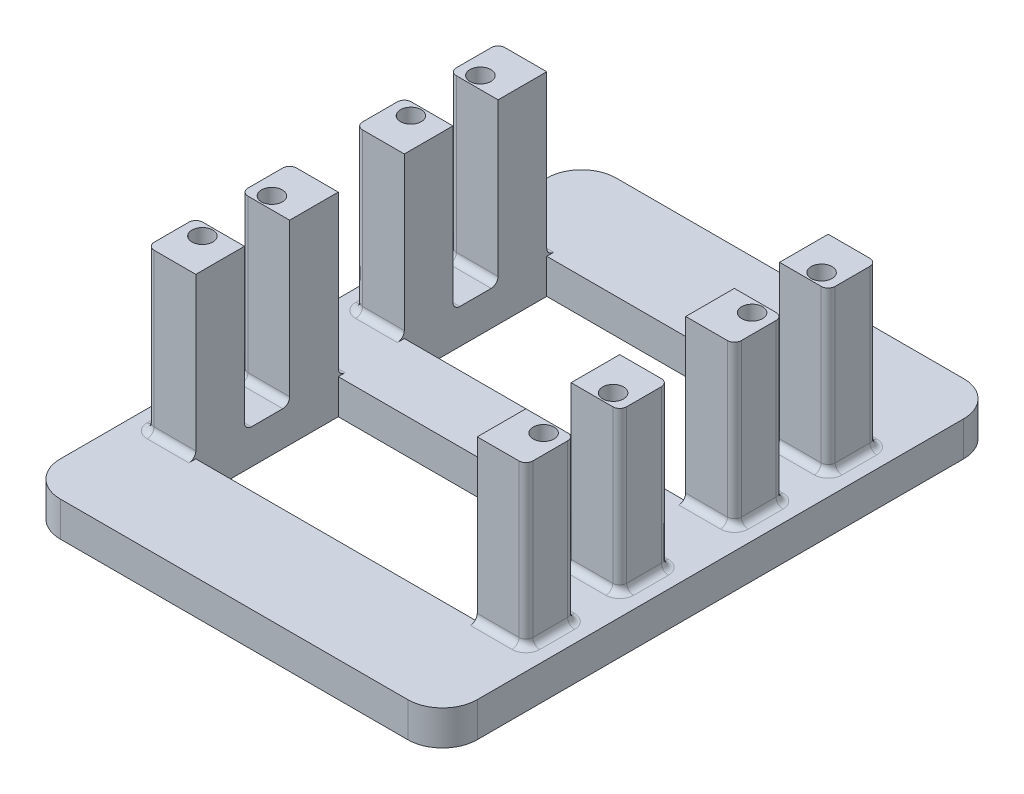
from build123d import *

# Parameters (mm, degrees)
SKETCH_1_W          = 60
SKETCH_1_H          = 80
EXTRUDE_1_DEPTH     = 5
SKETCH_2_W          = 40.5
SKETCH_2_H          = 20.5
CUT_EXTRUDE_1_DEPTH = 6
SKETCH_3_W          = 7
SKETCH_3_H          = 20.5
EXTRUDE_2_DEPTH     = 23
SKETCH_4_R          = 1.5
CUT_EXTRUDE_2_DEPTH = 10
FILLET_1_R          = 5
SKETCH_6_W          = 7
SKETCH_6_H          = 6.5
CUT_EXTRUDE_9_DEPTH = 23
FILLET_4_R          = 1
FILLET_6_R          = 1


with BuildPart() as part:
    # 草图1 → 凸台-拉伸1 (new body)
    with BuildSketch(Plane(origin=(0, 0, 0), x_dir=(1, 0, 0), z_dir=(0, 1, 0))):
        Rectangle(SKETCH_1_W, SKETCH_1_H)
    extrude(amount=EXTRUDE_1_DEPTH)

    # 草图2 → 切除-拉伸1 (cut, through all)
    with BuildSketch(Plane(origin=(0, 5, 0), x_dir=(1, 0, 0), z_dir=(0, 1, 0))):
        with Locations((0, -15)):
            Rectangle(SKETCH_2_W, SKETCH_2_H)
        with Locations((0, 15)):
            Rectangle(SKETCH_2_W, SKETCH_2_H)
    extrude(amount=-CUT_EXTRUDE_1_DEPTH, mode=Mode.SUBTRACT)

    # 草图3 → 凸台-拉伸2 (add)
    with BuildSketch(Plane(origin=(0, 5, 0), x_dir=(1, 0, 0), z_dir=(0, 1, 0))):
        with Locations((-23.75, 15)):
            Rectangle(SKETCH_3_W, SKETCH_3_H)
        with Locations((23.75, 15)):
            Rectangle(SKETCH_3_W, SKETCH_3_H)
        with Locations((23.75, -15)):
            Rectangle(SKETCH_3_W, SKETCH_3_H)
        with Locations((-23.75, -15)):
            Rectangle(SKETCH_3_W, SKETCH_3_H)
    extrude(amount=EXTRUDE_2_DEPTH)

    # 草图4 → 切除-拉伸2 (cut)
    with BuildSketch(Plane(origin=(0, 28, 0), x_dir=(1, 0, 0), z_dir=(0, 1, 0))):
        with Locations((-24.55, 20)):
            Circle(SKETCH_4_R)
        with Locations((-24.55, 10)):
            Circle(SKETCH_4_R)
        with Locations((24.55, 10)):
            Circle(SKETCH_4_R)
        with Locations((24.55, 20)):
            Circle(SKETCH_4_R)
        with Locations((24.55, -10)):
            Circle(SKETCH_4_R)
        with Locations((24.55, -20)):
            Circle(SKETCH_4_R)
        with Locations((-24.55, -10)):
            Circle(SKETCH_4_R)
        with Locations((-24.55, -20)):
            Circle(SKETCH_4_R)
    extrude(amount=-CUT_EXTRUDE_2_DEPTH, mode=Mode.SUBTRACT)

    # 圆角1
    fillet_1_edges = [part.edges().sort_by_distance(p)[0] for p in [
        (-30, 2.5, -40),
        (30, 2.5, -40),
        (30, 2.5, 40),
        (-30, 2.5, 40),
    ]]
    fillet(fillet_1_edges, radius=FILLET_1_R)

    # 草图6 → 切除-拉伸9 (cut)
    with BuildSketch(Plane(origin=(0, 28, 0), x_dir=(1, 0, 0), z_dir=(0, 1, 0))):
        with Locations((-23.75, 15)):
            Rectangle(SKETCH_6_W, SKETCH_6_H)
        with Locations((23.75, 15)):
            Rectangle(SKETCH_6_W, SKETCH_6_H)
        with Locations((23.75, -15)):
            Rectangle(SKETCH_6_W, SKETCH_6_H)
        with Locations((-23.75, -15)):
            Rectangle(SKETCH_6_W, SKETCH_6_H)
    extrude(amount=-CUT_EXTRUDE_9_DEPTH, mode=Mode.SUBTRACT)

    # 圆角4
    fillet_4_edges = [part.edges().sort_by_distance(p)[0] for p in [
        (-27.25, 16.5, 18.25),
        (-27.25, 16.5, 11.75),
        (27.25, 16.5, 11.75),
        (27.25, 16.5, 18.25),
        (27.25, 16.5, -18.25),
        (27.25, 16.5, -11.75),
        (-27.25, 16.5, -11.75),
        (-27.25, 16.5, -18.25),
        (-27.25, 16.5, -25.25),
        (-27.25, 16.5, -4.75),
        (27.25, 16.5, -4.75),
        (27.25, 16.5, -25.25),
        (27.25, 16.5, 25.25),
        (27.25, 16.5, 4.75),
        (-27.25, 16.5, 4.75),
        (-27.25, 16.5, 25.25),
    ]]
    fillet(fillet_4_edges, radius=FILLET_4_R)

    # 圆角6
    fillet_6_edges = [part.edges().sort_by_distance(p)[0] for p in [
        (-23.25, 5, 11.75),
        (23.25, 5, 18.25),
        (23.25, 5, -11.75),
        (-23.25, 5, -18.25),
        (23.25, 5, -25.25),
        (27.25, 5, -21.75),
        (23.25, 5, -18.25),
        (27.25, 5, -8.25),
        (23.25, 5, 4.75),
        (27.25, 5, 8.25),
        (23.25, 5, 11.75),
        (27.25, 5, 21.75),
        (-23.25, 5, 18.25),
        (-27.25, 5, 21.75),
        (-23.25, 5, 25.25),
        (-27.25, 5, 8.25),
        (-27.25, 5, -21.75),
        (-23.25, 5, -11.75),
        (-27.25, 5, -8.25),
        (-23.25, 5, -4.75),
        (26.957106781, 5, -24.957106781),
        (26.957106781, 5, -18.542893219),
        (26.957106781, 5, -11.457106781),
        (26.957106781, 5, -5.042893219),
        (26.957106781, 5, 5.042893219),
        (26.957106781, 5, 11.457106781),
        (26.957106781, 5, 18.542893219),
        (26.957106781, 5, 24.957106781),
        (-26.957106781, 5, 18.542893219),
        (-26.957106781, 5, 24.957106781),
        (-26.957106781, 5, 5.042893219),
        (-26.957106781, 5, 11.457106781),
        (-26.957106781, 5, -24.957106781),
        (-26.957106781, 5, -11.457106781),
        (-26.957106781, 5, -5.042893219),
        (-26.957106781, 5, -18.542893219),
        (-23.25, 5, -25.25),
        (23.25, 5, -4.75),
        (23.25, 5, 25.25),
        (-23.25, 5, 4.75),
    ]]
    fillet(fillet_6_edges, radius=FILLET_6_R)


solid = part.part
